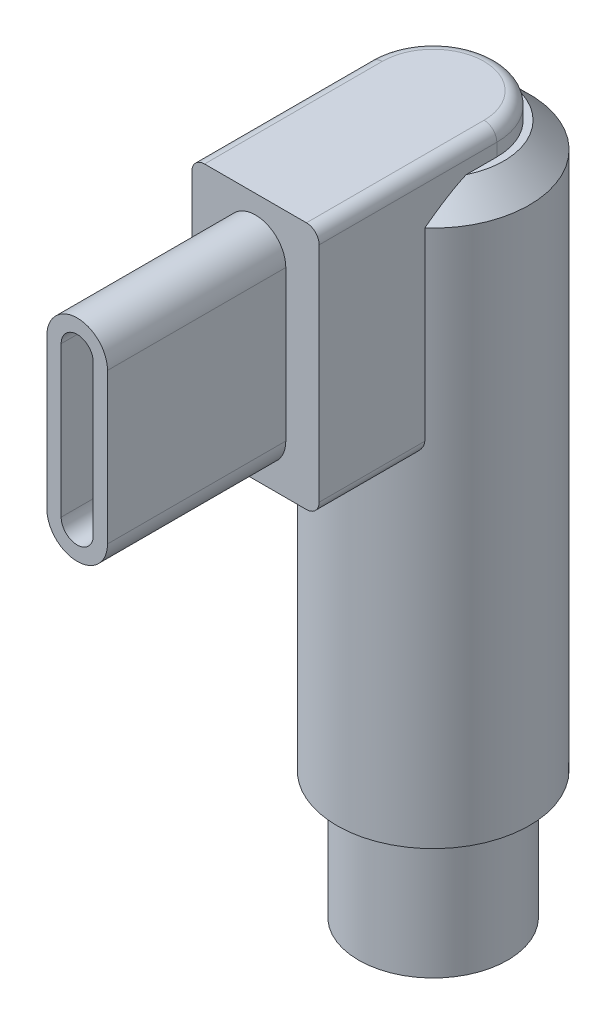
from build123d import *

# Parameters (mm, degrees)
SKETCH1_R           = 2.925
BOSS_EXTRUDE1_DEPTH = 5
SKETCH2_R           = 3.775
BOSS_EXTRUDE2_DEPTH = 23.1
BOSS_EXTRUDE3_START = -0.946462
SKETCH3_W           = 5
SKETCH3_H           = 9.75
BOSS_EXTRUDE3_DEPTH = 4.146462
BOSS_EXTRUDE4_DEPTH = 7
CUT_EXTRUDE1_DEPTH  = 1
CHAMFER1_SIZE       = 1
FILLET1_R           = 0.5


with BuildPart() as part:
    # Sketch1 → Boss-Extrude1 (new body)
    with BuildSketch(Plane(origin=(0, 0, 0), x_dir=(1, 0, 0), z_dir=(0, 1, 0))):
        Circle(SKETCH1_R)
    extrude(amount=BOSS_EXTRUDE1_DEPTH)

    # Sketch2 → Boss-Extrude2 (add)
    with BuildSketch(Plane(origin=(0, 5, 0), x_dir=(1, 0, 0), z_dir=(0, 1, 0))):
        Circle(SKETCH2_R)
    extrude(amount=BOSS_EXTRUDE2_DEPTH)

    # Sketch3 → Boss-Extrude3 (add)
    with BuildSketch(Plane.XY.offset(3.775).offset(BOSS_EXTRUDE3_START)):
        with Locations((0, 23.225)):
            Rectangle(SKETCH3_W, SKETCH3_H)
    extrude(amount=BOSS_EXTRUDE3_DEPTH)

    # Sketch4 → Boss-Extrude4 (add)
    with BuildSketch(Plane.XY.offset(6.975)):
        with BuildLine():
            Line((1.19, 26.175), (1.19, 20.275))
            ThreePointArc((1.19, 20.275), (0, 19.085), (-1.19, 20.275))
            Line((-1.19, 20.275), (-1.19, 26.175))
            ThreePointArc((-1.19, 26.175), (0, 27.365), (1.19, 26.175))
        make_face()
        with BuildLine():
            Line((0.63, 26.175), (0.63, 20.275))
            ThreePointArc((0.63, 20.275), (0, 19.645), (-0.63, 20.275))
            Line((-0.63, 20.275), (-0.63, 26.175))
            ThreePointArc((-0.63, 26.175), (0, 26.805), (0.63, 26.175))
        make_face(mode=Mode.SUBTRACT)
    extrude(amount=BOSS_EXTRUDE4_DEPTH)

    # Sketch5 → Cut-Extrude1 (cut)
    with BuildSketch(Plane(origin=(0, 28.1, 0), x_dir=(1, 0, 0), z_dir=(0, 1, 0))):
        with BuildLine():
            Line((2.5, 0), (2.5, -2.828537608))
            ThreePointArc((2.5, -2.828537608), (0, 3.775), (-2.5, -2.828537608))
            Line((-2.5, -2.828537608), (-2.5, 0))
            ThreePointArc((-2.5, 0), (0, 2.5), (2.5, 0))
        make_face()
    extrude(amount=-CUT_EXTRUDE1_DEPTH, mode=Mode.SUBTRACT)

    # Chamfer1
    chamfer1_edges = [part.edges().sort_by_distance(p)[0] for p in [
        (-1.55130993, 27.1, -3.441520376),
    ]]
    chamfer(chamfer1_edges, length=CHAMFER1_SIZE)

    # Fillet1
    fillet1_edges = [part.edges().sort_by_distance(p)[0] for p in [
        (-2.5, 28.1, 3.4875),
        (-2.5, 18.35, 4.901769),
        (2.5, 18.35, 4.901769),
        (2.5, 28.1, 3.4875),
        (0, 28.1, -2.5),
    ]]
    fillet(fillet1_edges, radius=FILLET1_R)


solid = part.part
